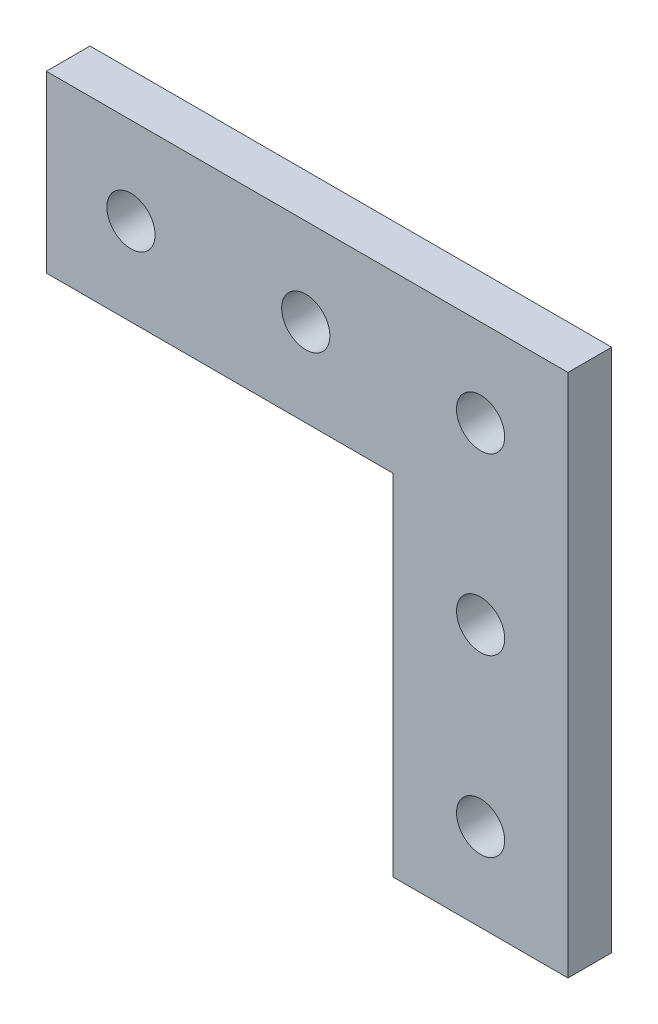
from build123d import *

# Parameters (mm, degrees)
BOSS_EXTRUDE1_DEPTH = 6.35
SKETCH2_R           = 3.5
CUT_EXTRUDE1_DEPTH  = 7.35


with BuildPart() as part:
    # Sketch1 → Boss-Extrude1 (new body)
    with BuildSketch(Plane.XY):
        Polygon((12.7, 0), (-12.7, 0), (-12.7, 50.8), (-63.1, 50.8), (-63.1, 76.2), (12.7, 76.2), (12.7, 50.8), align=None)
    extrude(amount=BOSS_EXTRUDE1_DEPTH)

    # Sketch2 → Cut-Extrude1 (cut, through all)
    with BuildSketch(Plane.XY.offset(6.35)):
        with Locations((0, 63.5)):
            Circle(SKETCH2_R)
        with Locations((-25.4, 63.5)):
            Circle(SKETCH2_R)
        with Locations((0, 38.1)):
            Circle(SKETCH2_R)
        with Locations((0, 12.7)):
            Circle(SKETCH2_R)
        with Locations((-50.8, 63.5)):
            Circle(SKETCH2_R)
    extrude(amount=-CUT_EXTRUDE1_DEPTH, mode=Mode.SUBTRACT)


solid = part.part
